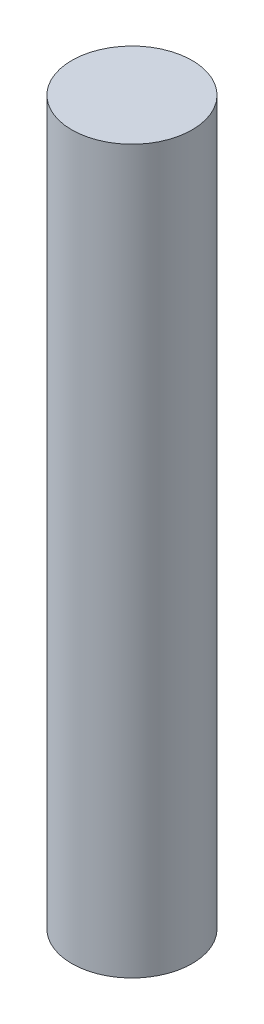
from build123d import *

# Parameters (mm, degrees)
SKETCH1_R           = 2.5
BOSS_EXTRUDE1_DEPTH = 30


with BuildPart() as part:
    # Sketch1 → Boss-Extrude1 (new body)
    with BuildSketch(Plane(origin=(0, 0, 0), x_dir=(1, 0, 0), z_dir=(0, 1, 0))):
        Circle(SKETCH1_R)
    extrude(amount=BOSS_EXTRUDE1_DEPTH)


solid = part.part
